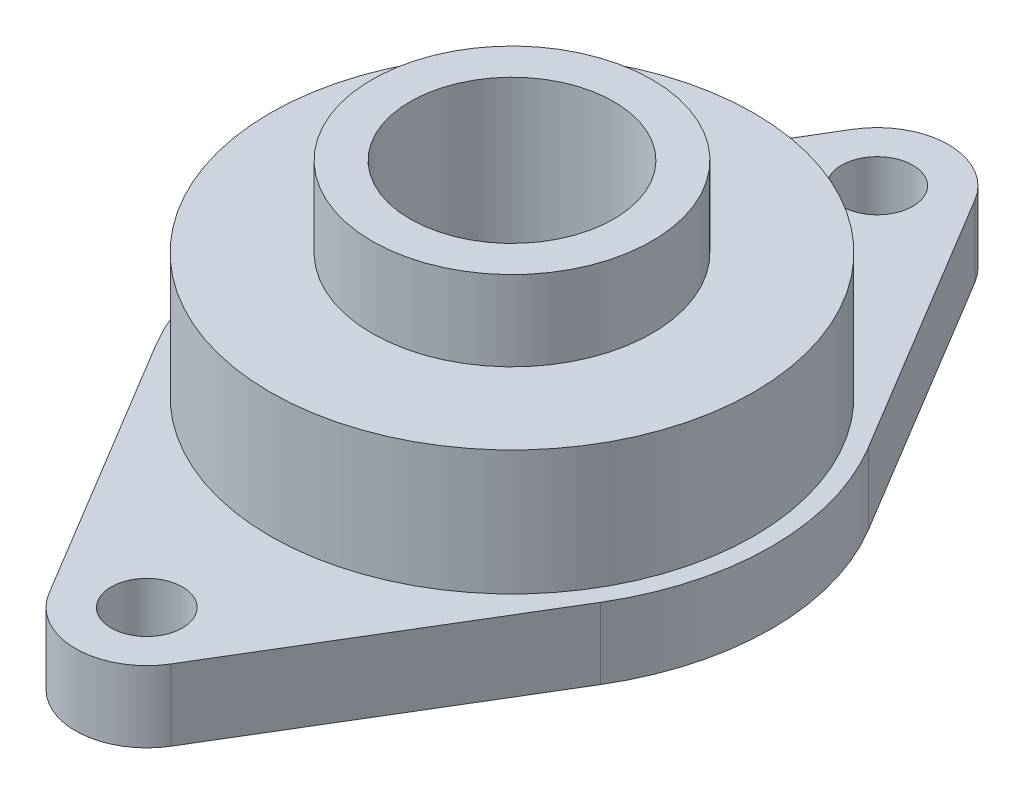
from build123d import *

# Parameters (mm, degrees)
SKETCH1_R           = 14
SKETCH1_R_2         = 7
SKETCH1_R_3         = 51
SKETCH1_R_4         = 20
BOSS_EXTRUDE1_DEPTH = 14
SKETCH2_R           = 47.5
SKETCH2_R_2         = 20
BOSS_EXTRUDE2_DEPTH = 24.5
SKETCH3_R           = 27.5
SKETCH3_R_2         = 20
BOSS_EXTRUDE3_DEPTH = 15.7


with BuildPart() as part:
    # Sketch1 → Boss-Extrude1 (new body)
    with BuildSketch(Plane(origin=(0, 0, 0), x_dir=(1, 0, 0), z_dir=(0, 1, 0))):
        with Locations((0, 71.75)):
            Circle(SKETCH1_R)
        with Locations((0, 71.75)):
            Circle(SKETCH1_R_2, mode=Mode.SUBTRACT)
        with BuildLine():
            Line((43.695861674, 26.299651568), (11.99494242, 78.969512195))
            ThreePointArc((11.99494242, 78.969512195), (13.489425375, 75.496385332), (14, 71.75))
            ThreePointArc((14, 71.75), (-3.746385332, 58.260574625), (-11.99494242, 78.969512195))
            Line((-11.99494242, 78.969512195), (-43.695861674, 26.299651568))
            ThreePointArc((-43.695861674, 26.299651568), (0, 51), (43.695861674, 26.299651568))
        make_face()
        with BuildLine():
            ThreePointArc((43.695861674, -26.299651568), (0, -51), (-43.695861674, -26.299651568))
            Line((-43.695861674, -26.299651568), (-11.99494242, -78.969512195))
            ThreePointArc((-11.99494242, -78.969512195), (-3.746385332, -58.260574625), (14, -71.75))
            ThreePointArc((14, -71.75), (13.489425375, -75.496385332), (11.99494242, -78.969512195))
            Line((11.99494242, -78.969512195), (43.695861674, -26.299651568))
        make_face()
        with Locations((0, -71.75)):
            Circle(SKETCH1_R)
        with Locations((0, -71.75)):
            Circle(SKETCH1_R_2, mode=Mode.SUBTRACT)
        Circle(SKETCH1_R_3)
        Circle(SKETCH1_R_4, mode=Mode.SUBTRACT)
    extrude(amount=BOSS_EXTRUDE1_DEPTH)

    # Sketch2 → Boss-Extrude2 (add)
    with BuildSketch(Plane(origin=(0, 14, 0), x_dir=(1, 0, 0), z_dir=(0, 1, 0))):
        Circle(SKETCH2_R)
        Circle(SKETCH2_R_2, mode=Mode.SUBTRACT)
    extrude(amount=BOSS_EXTRUDE2_DEPTH)

    # Sketch3 → Boss-Extrude3 (add)
    with BuildSketch(Plane(origin=(0, 38.5, 0), x_dir=(1, 0, 0), z_dir=(0, 1, 0))):
        Circle(SKETCH3_R)
        Circle(SKETCH3_R_2, mode=Mode.SUBTRACT)
    extrude(amount=BOSS_EXTRUDE3_DEPTH)


solid = part.part
